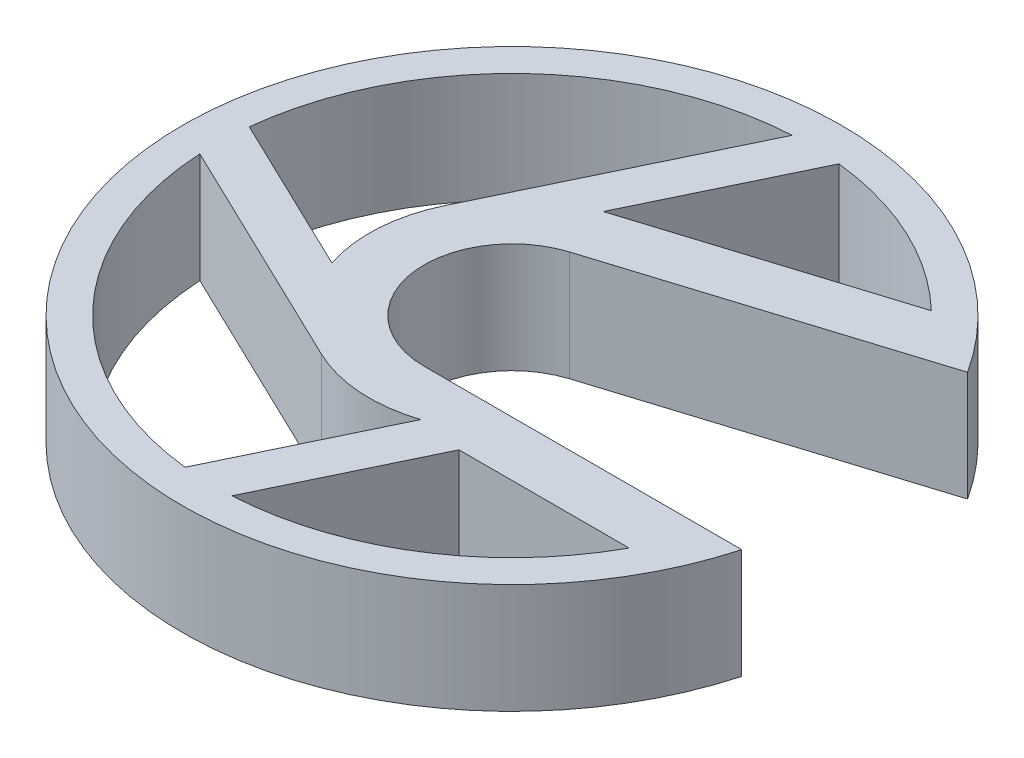
from build123d import *

# Parameters (mm, degrees)
EXTRUDE_1_DEPTH = 5


with BuildPart() as part:
    # 草图1 → 凸台-拉伸1 (new body)
    with BuildSketch(Plane(origin=(0, 0, 0), x_dir=(1, 0, 0), z_dir=(0, 1, 0))):
        with BuildLine():
            ThreePointArc((-46.803501746, 8.133377636), (-74.235016913, -2.264931442), (-44.950167705, -4))
            Line((-44.950167705, -4), (-59.407, -4))
            ThreePointArc((-59.407, -4), (-63.361137843, -0.603981718), (-60.601113484, 3.817603042))
            Line((-60.601113484, 3.817603042), (-46.803501746, 8.133377636))
        make_face()
        with BuildLine():
            Line((-60.13775005, 13.480207875), (-65.265019195, 2.816666667))
            ThreePointArc((-65.265019195, 2.816666667), (-65.892913632, 0.427696579), (-65.584160854, -2.023038254))
            Line((-65.584160854, -2.023038254), (-72.827832577, 1.459881143))
            ThreePointArc((-72.827832577, 1.459881143), (-68.690796982, 9.801077165), (-60.13775005, 13.480207875))
        make_face(mode=Mode.SUBTRACT)
        with BuildLine():
            Line((-72.887207875, -0.73075005), (-62.223666667, -5.858019195))
            ThreePointArc((-62.223666667, -5.858019195), (-59.834696579, -6.485913632), (-57.383961746, -6.177160854))
            Line((-57.383961746, -6.177160854), (-60.866881143, -13.420832577))
            ThreePointArc((-60.866881143, -13.420832577), (-69.208077165, -9.283796982), (-72.887207875, -0.73075005))
        make_face(mode=Mode.SUBTRACT)
        with BuildLine():
            Line((-58.67624995, -13.480207875), (-55.320009864, -6.5))
            Line((-55.320009864, -6.5), (-47.574840434, -6.5))
            ThreePointArc((-47.574840434, -6.5), (-52.22107626, -11.428582589), (-58.67624995, -13.480207875))
        make_face(mode=Mode.SUBTRACT)
        with BuildLine():
            ThreePointArc((-57.947118857, 13.420832577), (-53.695607864, 12.232334195), (-50.054812322, 9.735840264))
            Line((-50.054812322, 9.735840264), (-61.347434411, 6.203604944))
            ThreePointArc((-61.347434411, 6.203604944), (-61.388780441, 6.19052068), (-61.430038254, 6.177160854))
            Line((-61.430038254, 6.177160854), (-57.947118857, 13.420832577))
        make_face(mode=Mode.SUBTRACT)
    extrude(amount=EXTRUDE_1_DEPTH)


solid = part.part
